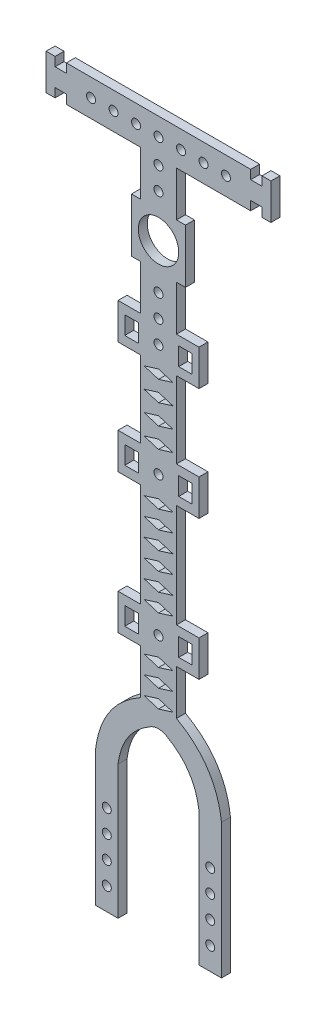
from build123d import *

# Parameters (mm, degrees)
SKETCH_1_R      = 4.5
SKETCH_1_R_2    = 1
SKETCH_1_W      = 3
SKETCH_1_H      = 4
EXTRUDE_1_DEPTH = 2


with BuildPart() as part:
    # 草图1 → 凸台-拉伸1 (new body)
    with BuildSketch(Plane.XY):
        with BuildLine():
            Line((6, 6), (4, 6))
            Line((4, 6), (4, 16))
            Line((4, 16), (20.5, 16))
            Line((20.5, 16), (20.5, 18))
            Line((20.5, 18), (23, 18))
            Line((23, 18), (23, 16))
            Line((23, 16), (25, 16))
            Line((25, 16), (25, 24))
            Line((25, 24), (23, 24))
            Line((23, 24), (23, 22))
            Line((23, 22), (20.5, 22))
            Line((20.5, 22), (20.5, 24))
            Line((20.5, 24), (-20.5, 24))
            Line((-20.5, 24), (-20.5, 22))
            Line((-20.5, 22), (-23, 22))
            Line((-23, 22), (-23, 24))
            Line((-23, 24), (-25, 24))
            Line((-25, 24), (-25, 16))
            Line((-25, 16), (-23, 16))
            Line((-23, 16), (-23, 18))
            Line((-23, 18), (-20.5, 18))
            Line((-20.5, 18), (-20.5, 16))
            Line((-20.5, 16), (-4, 16))
            Line((-4, 16), (-4, 6))
            Line((-4, 6), (-6, 6))
            Line((-6, 6), (-6, -6))
            Line((-6, -6), (-4, -6))
            Line((-4, -6), (-4, -16))
            Line((-4, -16), (-9, -16))
            Line((-9, -16), (-9, -24))
            Line((-9, -24), (-4, -24))
            Line((-4, -24), (-4, -41))
            Line((-4, -41), (-9, -41))
            Line((-9, -41), (-9, -49))
            Line((-9, -49), (-4, -49))
            Line((-4, -49), (-4, -72))
            Line((-4, -72), (-9, -72))
            Line((-9, -72), (-9, -80))
            Line((-9, -80), (-4, -80))
            Line((-4, -80), (-4, -90))
            add(Edge.make_bspline(
                [(-4, -90), (-12.824800186, -94.946472906), (-14, -105)],
                knots=[0, 0, 0, 1, 1, 1], degree=2))
            Line((-14, -105), (-14, -135))
            Line((-14, -135), (-9, -135))
            Line((-9, -135), (-9, -105.307652325))
            add(Edge.make_bspline(
                [(-1.555258324, -94.361563726), (-4.124118351, -95.824075576), (-6.772437427, -98.85168045), (-8.60156745, -102.414074006), (-9, -105.307652325)],
                knots=[0, 0, 0, 0.368595186, 0.61432531, 0.982920497, 0.982920497, 0.982920497], degree=2))
            add(Edge.make_bspline(
                [(-1.555258324, -94.361563726), (0, -93.652312688), (1.555258324, -94.361563726)],
                knots=[0, 0, 0, 1, 1, 1], degree=2))
            add(Edge.make_bspline(
                [(1.555258324, -94.361563726), (4.124118351, -95.824075576), (6.772437427, -98.85168045), (8.60156745, -102.414074006), (9, -105.307652325)],
                knots=[0, 0, 0, 0.368595186, 0.61432531, 0.982920497, 0.982920497, 0.982920497], degree=2))
            Line((9, -105.307652325), (9, -135))
            Line((9, -135), (14, -135))
            Line((14, -135), (14, -105))
            add(Edge.make_bspline(
                [(4, -90), (12.824800186, -94.946472906), (14, -105)],
                knots=[0, 0, 0, 1, 1, 1], degree=2))
            Line((4, -90), (4, -80))
            Line((4, -80), (9, -80))
            Line((9, -80), (9, -72))
            Line((9, -72), (4, -72))
            Line((4, -72), (4, -49))
            Line((4, -49), (9, -49))
            Line((9, -49), (9, -41))
            Line((9, -41), (4, -41))
            Line((4, -41), (4, -24))
            Line((4, -24), (9, -24))
            Line((9, -24), (9, -16))
            Line((9, -16), (4, -16))
            Line((4, -16), (4, -6))
            Line((4, -6), (6, -6))
            Line((6, -6), (6, 6))
        make_face()
        Circle(SKETCH_1_R, mode=Mode.SUBTRACT)
        with Locations((15, 20.000000004)):
            Circle(SKETCH_1_R_2, mode=Mode.SUBTRACT)
        with Locations((-15, 20.000000004)):
            Circle(SKETCH_1_R_2, mode=Mode.SUBTRACT)
        with Locations((-10, 20.000000004)):
            Circle(SKETCH_1_R_2, mode=Mode.SUBTRACT)
        with Locations((-5, 20.000000004)):
            Circle(SKETCH_1_R_2, mode=Mode.SUBTRACT)
        with Locations((0, 14.54049212)):
            Circle(SKETCH_1_R_2, mode=Mode.SUBTRACT)
        with Locations((0, 9.54049212)):
            Circle(SKETCH_1_R_2, mode=Mode.SUBTRACT)
        with Locations((0, 20.000000004)):
            Circle(SKETCH_1_R_2, mode=Mode.SUBTRACT)
        with Locations((5, 20.000000004)):
            Circle(SKETCH_1_R_2, mode=Mode.SUBTRACT)
        with Locations((10, 20.000000004)):
            Circle(SKETCH_1_R_2, mode=Mode.SUBTRACT)
        with Locations((6, -20)):
            Rectangle(SKETCH_1_W, SKETCH_1_H, mode=Mode.SUBTRACT)
        with Locations((-11.5, -130)):
            Circle(SKETCH_1_R_2, mode=Mode.SUBTRACT)
        with Locations((-11.5, -125)):
            Circle(SKETCH_1_R_2, mode=Mode.SUBTRACT)
        with Locations((-11.5, -120)):
            Circle(SKETCH_1_R_2, mode=Mode.SUBTRACT)
        with Locations((-11.5, -115)):
            Circle(SKETCH_1_R_2, mode=Mode.SUBTRACT)
        with Locations((-6, -76)):
            Rectangle(SKETCH_1_W, SKETCH_1_H, mode=Mode.SUBTRACT)
        with Locations((11.5, -130)):
            Circle(SKETCH_1_R_2, mode=Mode.SUBTRACT)
        with Locations((11.5, -125)):
            Circle(SKETCH_1_R_2, mode=Mode.SUBTRACT)
        with Locations((11.5, -120)):
            Circle(SKETCH_1_R_2, mode=Mode.SUBTRACT)
        with Locations((11.5, -115)):
            Circle(SKETCH_1_R_2, mode=Mode.SUBTRACT)
        Polygon((-3.2, -89.2), (0, -88.2), (3.2, -89.2), (0, -90.2), align=None, mode=Mode.SUBTRACT)
        Polygon((-3.2, -85.2), (0, -84.2), (3.2, -85.2), (0, -86.2), align=None, mode=Mode.SUBTRACT)
        Polygon((-3.2, -81.2), (0, -80.2), (3.2, -81.2), (0, -82.2), align=None, mode=Mode.SUBTRACT)
        with Locations((6, -76)):
            Rectangle(SKETCH_1_W, SKETCH_1_H, mode=Mode.SUBTRACT)
        with Locations((0, -76)):
            Circle(SKETCH_1_R_2, mode=Mode.SUBTRACT)
        Polygon((-3.2, -70.7), (0, -69.7), (3.2, -70.7), (0, -71.7), align=None, mode=Mode.SUBTRACT)
        Polygon((-3.2, -66.7), (0, -65.7), (3.2, -66.7), (0, -67.7), align=None, mode=Mode.SUBTRACT)
        Polygon((-3.2, -62.7), (0, -61.7), (3.2, -62.7), (0, -63.7), align=None, mode=Mode.SUBTRACT)
        Polygon((-3.2, -58.7), (0, -57.7), (3.2, -58.7), (0, -59.7), align=None, mode=Mode.SUBTRACT)
        with Locations((-6, -45)):
            Rectangle(SKETCH_1_W, SKETCH_1_H, mode=Mode.SUBTRACT)
        Polygon((-3.2, -39.2), (0, -38.2), (3.2, -39.2), (0, -40.2), align=None, mode=Mode.SUBTRACT)
        Polygon((-3.2, -34.7), (0, -33.7), (3.2, -34.7), (0, -35.7), align=None, mode=Mode.SUBTRACT)
        Polygon((-3.2, -30.2), (0, -29.2), (3.2, -30.2), (0, -31.2), align=None, mode=Mode.SUBTRACT)
        Polygon((-3.2, -25.7), (0, -24.7), (3.2, -25.7), (0, -26.7), align=None, mode=Mode.SUBTRACT)
        with Locations((-6, -20)):
            Rectangle(SKETCH_1_W, SKETCH_1_H, mode=Mode.SUBTRACT)
        with Locations((0, -15)):
            Circle(SKETCH_1_R_2, mode=Mode.SUBTRACT)
        with Locations((0, -10)):
            Circle(SKETCH_1_R_2, mode=Mode.SUBTRACT)
        Polygon((-3.2, -54.7), (0, -53.7), (3.2, -54.7), (0, -55.7), align=None, mode=Mode.SUBTRACT)
        Polygon((-3.2, -50.7), (0, -49.7), (3.2, -50.7), (0, -51.7), align=None, mode=Mode.SUBTRACT)
        with Locations((0, -45)):
            Circle(SKETCH_1_R_2, mode=Mode.SUBTRACT)
        with Locations((6, -45)):
            Rectangle(SKETCH_1_W, SKETCH_1_H, mode=Mode.SUBTRACT)
        with Locations((0, -20)):
            Circle(SKETCH_1_R_2, mode=Mode.SUBTRACT)
    extrude(amount=EXTRUDE_1_DEPTH)


solid = part.part
